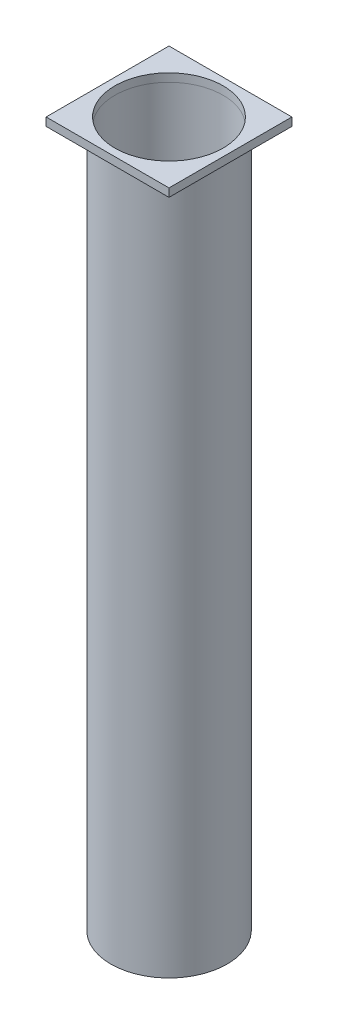
from build123d import *

# Parameters (mm, degrees)
SKETCH1_R           = 71
SKETCH1_R_2         = 66
BOSS_EXTRUDE1_DEPTH = 850
SKETCH2_W           = 150
SKETCH2_H           = 150
SKETCH2_R           = 66
BOSS_EXTRUDE2_DEPTH = 10


with BuildPart() as part:
    # Sketch1 → Boss-Extrude1 (new body)
    with BuildSketch(Plane(origin=(0, 0, 0), x_dir=(1, 0, 0), z_dir=(0, 1, 0))):
        Circle(SKETCH1_R)
        Circle(SKETCH1_R_2, mode=Mode.SUBTRACT)
    extrude(amount=BOSS_EXTRUDE1_DEPTH)


with BuildPart() as body_2:
    # Sketch2 → Boss-Extrude2 (new body)
    with BuildSketch(Plane(origin=(0, 850, 0), x_dir=(1, 0, 0), z_dir=(0, 1, 0))):
        Rectangle(SKETCH2_W, SKETCH2_H)
        Circle(SKETCH2_R, mode=Mode.SUBTRACT)
    extrude(amount=BOSS_EXTRUDE2_DEPTH)


solid = Compound([part.part, body_2.part])
